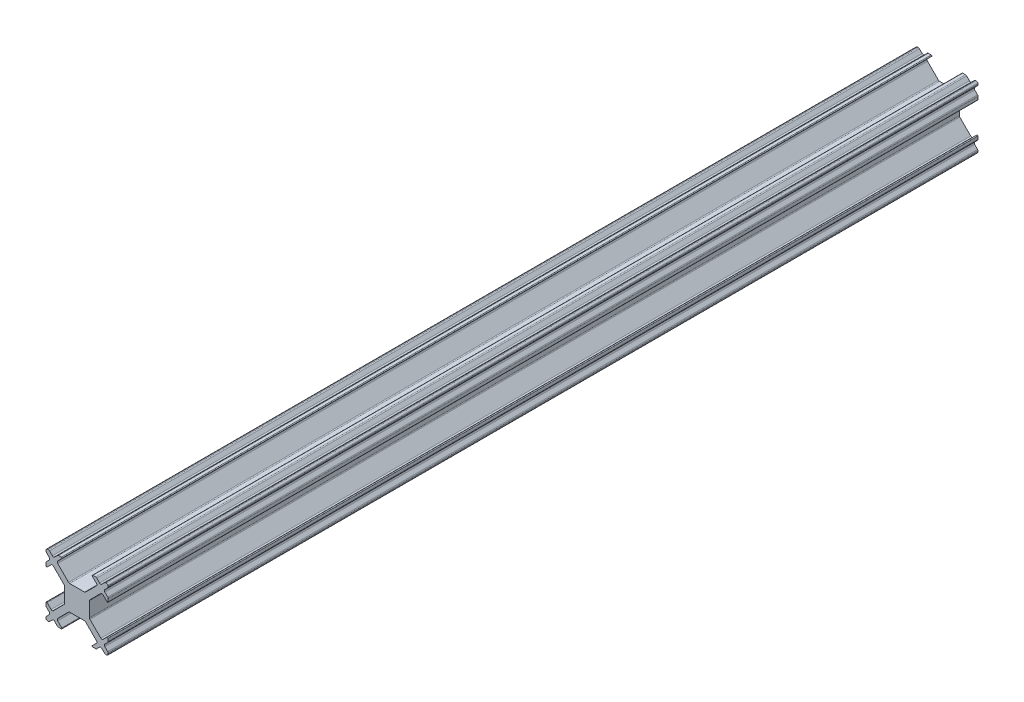
from build123d import *

# Parameters (mm, degrees)
BOSS_EXTRUDE1_DEPTH = 140


with BuildPart() as part:
    # Sketch1 → Boss-Extrude1 (new body)
    with BuildSketch(Plane.XY):
        with BuildLine():
            Line((-26.434620061, 28.496491655), (-25.979594809, 28.951516907))
            ThreePointArc((-25.979594809, 28.951516907), (-25.906371503, 29.128293603), (-25.979594808, 29.305070299))
            Line((-25.979594808, 29.305070299), (-26.43462006, 29.760095551))
            ThreePointArc((-26.43462006, 29.760095551), (-26.488813248, 29.841201388), (-26.507843365, 29.936872247))
            Line((-26.507843365, 29.936872247), (-26.507843365, 30.078293605))
            ThreePointArc((-26.507843365, 30.078293605), (-26.43462006, 30.255070299), (-26.257843366, 30.328293604))
            Line((-26.257843366, 30.328293604), (-26.11642201, 30.328293604))
            ThreePointArc((-26.11642201, 30.328293604), (-26.020751153, 30.309263487), (-25.939645316, 30.255070299))
            Line((-25.939645316, 30.255070299), (-25.484620061, 29.800045045))
            ThreePointArc((-25.484620061, 29.800045045), (-25.307843366, 29.72682174), (-25.131066671, 29.800045045))
            Line((-25.131066671, 29.800045045), (-24.676041418, 30.255070298))
            ThreePointArc((-24.676041418, 30.255070298), (-24.594935581, 30.309263487), (-24.499264722, 30.328293604))
            Line((-24.499264722, 30.328293604), (-24.042157942, 30.328293604))
            ThreePointArc((-24.042157942, 30.328293604), (-23.949769989, 30.266561947), (-23.971447265, 30.157582926))
            Line((-23.971447265, 30.157582926), (-24.623959891, 29.505070299))
            ThreePointArc((-24.623959891, 29.505070299), (-24.697183196, 29.328293604), (-24.623959891, 29.15151691))
            Line((-24.623959891, 29.15151691), (-22.873959891, 27.401516909))
            ThreePointArc((-22.873959891, 27.401516909), (-22.792854054, 27.347323722), (-22.697183196, 27.328293605))
            Line((-22.697183196, 27.328293605), (-20.318503539, 27.328293605))
            ThreePointArc((-20.318503539, 27.328293605), (-20.222832681, 27.347323722), (-20.141726844, 27.401516909))
            Line((-20.141726844, 27.401516909), (-18.391726844, 29.15151691))
            ThreePointArc((-18.391726844, 29.15151691), (-18.318503539, 29.328293604), (-18.391726844, 29.505070299))
            Line((-18.391726844, 29.505070299), (-19.04423947, 30.157582926))
            ThreePointArc((-19.04423947, 30.157582926), (-19.065916745, 30.266561947), (-18.973528793, 30.328293604))
            Line((-18.973528793, 30.328293604), (-18.516422013, 30.328293604))
            ThreePointArc((-18.516422013, 30.328293604), (-18.420751155, 30.309263487), (-18.339645319, 30.2550703))
            Line((-18.339645319, 30.2550703), (-17.884620064, 29.800045045))
            ThreePointArc((-17.884620064, 29.800045045), (-17.707843369, 29.72682174), (-17.531066674, 29.800045045))
            Line((-17.531066674, 29.800045045), (-17.07604142, 30.2550703))
            ThreePointArc((-17.07604142, 30.2550703), (-16.994935583, 30.309263487), (-16.899264725, 30.328293604))
            Line((-16.899264725, 30.328293604), (-16.75784337, 30.328293604))
            ThreePointArc((-16.75784337, 30.328293604), (-16.581066675, 30.255070299), (-16.507843371, 30.078293605))
            Line((-16.507843371, 30.078293605), (-16.507843371, 29.936872247))
            ThreePointArc((-16.507843371, 29.936872247), (-16.526873488, 29.841201389), (-16.581066675, 29.760095552))
            Line((-16.581066675, 29.760095552), (-17.036091927, 29.3050703))
            ThreePointArc((-17.036091927, 29.3050703), (-17.109315232, 29.128293603), (-17.036091926, 28.951516907))
            Line((-17.036091926, 28.951516907), (-16.581066674, 28.496491655))
            ThreePointArc((-16.581066674, 28.496491655), (-16.526873486, 28.415385818), (-16.507843369, 28.31971496))
            Line((-16.507843369, 28.31971496), (-16.507843369, 27.862608178))
            ThreePointArc((-16.507843369, 27.862608178), (-16.569575025, 27.770220231), (-16.678554041, 27.791897499))
            Line((-16.678554041, 27.791897499), (-17.331066668, 28.444410126))
            ThreePointArc((-17.331066668, 28.444410126), (-17.507843364, 28.517633431), (-17.68462006, 28.444410125))
            Line((-17.68462006, 28.444410125), (-19.434620061, 26.694410125))
            ThreePointArc((-19.434620061, 26.694410125), (-19.488813248, 26.613304288), (-19.507843364, 26.51763343))
            Line((-19.507843364, 26.51763343), (-19.507843364, 24.138953775))
            ThreePointArc((-19.507843364, 24.138953775), (-19.488813247, 24.043282917), (-19.434620059, 23.962177079))
            Line((-19.434620059, 23.962177079), (-17.684620059, 22.212177079))
            ThreePointArc((-17.684620059, 22.212177079), (-17.507843363, 22.138953773), (-17.331066666, 22.212177077))
            Line((-17.331066666, 22.212177077), (-16.67855404, 22.864689704))
            ThreePointArc((-16.67855404, 22.864689704), (-16.569575019, 22.886366979), (-16.507843363, 22.793979027))
            Line((-16.507843363, 22.793979027), (-16.507843363, 22.336872245))
            ThreePointArc((-16.507843363, 22.336872245), (-16.52687348, 22.241201387), (-16.581066668, 22.16009555))
            Line((-16.581066668, 22.16009555), (-17.036091921, 21.705070296))
            ThreePointArc((-17.036091921, 21.705070296), (-17.109315225, 21.528293601), (-17.036091921, 21.351516906))
            Line((-17.036091921, 21.351516906), (-16.581066669, 20.896491654))
            ThreePointArc((-16.581066669, 20.896491654), (-16.526873481, 20.815385817), (-16.507843364, 20.719714959))
            Line((-16.507843364, 20.719714959), (-16.507843364, 20.578293601))
            ThreePointArc((-16.507843364, 20.578293601), (-16.581066669, 20.401516906), (-16.757843364, 20.328293601))
            Line((-16.757843364, 20.328293601), (-16.89926472, 20.328293601))
            ThreePointArc((-16.89926472, 20.328293601), (-16.994935578, 20.347323718), (-17.076041415, 20.401516905))
            Line((-17.076041415, 20.401516905), (-17.53106667, 20.85654216))
            ThreePointArc((-17.53106667, 20.85654216), (-17.707843365, 20.929765464), (-17.88462006, 20.85654216))
            Line((-17.88462006, 20.85654216), (-18.339645314, 20.401516905))
            ThreePointArc((-18.339645314, 20.401516905), (-18.420751151, 20.347323718), (-18.516422009, 20.328293601))
            Line((-18.516422009, 20.328293601), (-18.973528789, 20.328293601))
            ThreePointArc((-18.973528789, 20.328293601), (-19.065916743, 20.390025258), (-19.044239468, 20.499004281))
            Line((-19.044239468, 20.499004281), (-18.391726841, 21.151516907))
            ThreePointArc((-18.391726841, 21.151516907), (-18.318503536, 21.328293602), (-18.391726841, 21.505070297))
            Line((-18.391726841, 21.505070297), (-20.141726841, 23.255070297))
            ThreePointArc((-20.141726841, 23.255070297), (-20.222832678, 23.309263485), (-20.318503536, 23.328293602))
            Line((-20.318503536, 23.328293602), (-22.697183193, 23.328293602))
            ThreePointArc((-22.697183193, 23.328293602), (-22.792854051, 23.309263485), (-22.873959889, 23.255070297))
            Line((-22.873959889, 23.255070297), (-24.623959889, 21.505070297))
            ThreePointArc((-24.623959889, 21.505070297), (-24.697183193, 21.328293602), (-24.623959889, 21.151516907))
            Line((-24.623959889, 21.151516907), (-23.971447262, 20.499004281))
            ThreePointArc((-23.971447262, 20.499004281), (-23.949769986, 20.390025258), (-24.042157941, 20.328293601))
            Line((-24.042157941, 20.328293601), (-24.49926472, 20.328293601))
            ThreePointArc((-24.49926472, 20.328293601), (-24.594935579, 20.347323718), (-24.676041417, 20.401516907))
            Line((-24.676041417, 20.401516907), (-25.131066671, 20.85654216))
            ThreePointArc((-25.131066671, 20.85654216), (-25.307843365, 20.929765464), (-25.48462006, 20.85654216))
            Line((-25.48462006, 20.85654216), (-25.939645315, 20.401516906))
            ThreePointArc((-25.939645315, 20.401516906), (-26.020751152, 20.347323718), (-26.11642201, 20.328293601))
            Line((-26.11642201, 20.328293601), (-26.257843366, 20.328293601))
            ThreePointArc((-26.257843366, 20.328293601), (-26.434620061, 20.401516906), (-26.507843366, 20.578293601))
            Line((-26.507843366, 20.578293601), (-26.507843366, 20.719714959))
            ThreePointArc((-26.507843366, 20.719714959), (-26.488813249, 20.815385817), (-26.434620061, 20.896491655))
            Line((-26.434620061, 20.896491655), (-25.979594809, 21.351516907))
            ThreePointArc((-25.979594809, 21.351516907), (-25.906371505, 21.528293602), (-25.979594809, 21.705070297))
            Line((-25.979594809, 21.705070297), (-26.434620063, 22.16009555))
            ThreePointArc((-26.434620063, 22.16009555), (-26.48881325, 22.241201387), (-26.507843367, 22.336872245))
            Line((-26.507843367, 22.336872245), (-26.507843367, 22.793979027))
            ThreePointArc((-26.507843367, 22.793979027), (-26.446111711, 22.88636698), (-26.337132691, 22.864689705))
            Line((-26.337132691, 22.864689705), (-25.684620064, 22.212177078))
            ThreePointArc((-25.684620064, 22.212177078), (-25.507843369, 22.138953774), (-25.331066674, 22.212177078))
            Line((-25.331066674, 22.212177078), (-23.581066674, 23.962177078))
            ThreePointArc((-23.581066674, 23.962177078), (-23.526873485, 24.043282916), (-23.507843368, 24.138953775))
            Line((-23.507843368, 24.138953775), (-23.507843368, 26.51763343))
            ThreePointArc((-23.507843368, 26.51763343), (-23.526873484, 26.613304288), (-23.581066672, 26.694410125))
            Line((-23.581066672, 26.694410125), (-25.331066672, 28.444410125))
            ThreePointArc((-25.331066672, 28.444410125), (-25.507843367, 28.51763343), (-25.684620062, 28.444410125))
            Line((-25.684620062, 28.444410125), (-26.337132689, 27.791897498))
            ThreePointArc((-26.337132689, 27.791897498), (-26.44611171, 27.770220225), (-26.507843366, 27.862608178))
            Line((-26.507843366, 27.862608178), (-26.507843366, 28.31971496))
            ThreePointArc((-26.507843366, 28.31971496), (-26.488813249, 28.415385818), (-26.434620061, 28.496491655))
        make_face()
    extrude(amount=BOSS_EXTRUDE1_DEPTH)


solid = part.part
